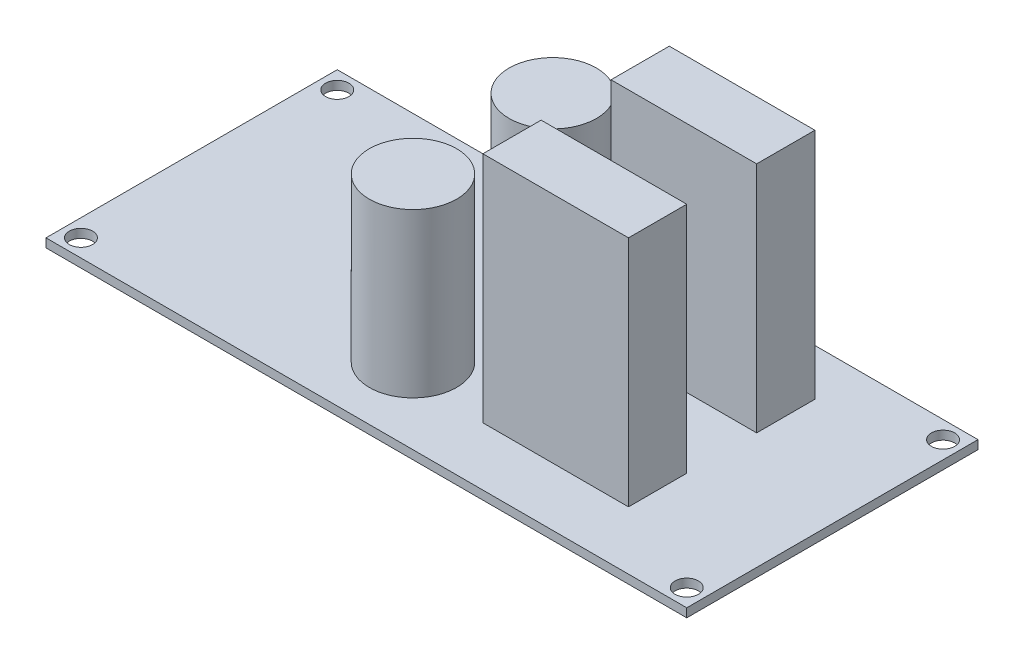
from build123d import *

# Parameters (mm, degrees)
ESBO_O1_W                = 110
ESBO_O1_H                = 50
RESSALTO_EXTRUS_O1_DEPTH = 1.5
ESBO_O2_R                = 2
CORTE_EXTRUS_O1_DEPTH    = 1.5
ESBO_O4_R                = 7.5
ESBO_O4_W                = 25
ESBO_O4_H                = 10
RESSALTO_EXTRUS_O3_DEPTH = 40
ESBO_O5_W                = 39
ESBO_O5_H                = 12
CORTE_EXTRUS_O2_DEPTH    = 60


with BuildPart() as part:
    # Esboço1 → Ressalto-extrusão1 (new body)
    with BuildSketch(Plane(origin=(0, 0, 0), x_dir=(1, 0, 0), z_dir=(0, 1, 0))):
        with Locations((55, 25)):
            Rectangle(ESBO_O1_W, ESBO_O1_H)
    extrude(amount=RESSALTO_EXTRUS_O1_DEPTH)

    # Esboço2 → Corte-extrusão1 (cut)
    with BuildSketch(Plane(origin=(0, 1.5, 0), x_dir=(1, 0, 0), z_dir=(0, 1, 0))):
        with Locations((107, 3)):
            Circle(ESBO_O2_R)
        with Locations((107, 47)):
            Circle(ESBO_O2_R)
        with Locations((3, 3)):
            Circle(ESBO_O2_R)
        with Locations((3, 47)):
            Circle(ESBO_O2_R)
    extrude(amount=-CORTE_EXTRUS_O1_DEPTH, mode=Mode.SUBTRACT)

    # Esboço4 → Ressalto-extrusão3 (add)
    with BuildSketch(Plane(origin=(0, 1.5, 0), x_dir=(1, 0, 0), z_dir=(0, 1, 0))):
        with Locations((50, 37)):
            Circle(ESBO_O4_R)
        with Locations((50, 13)):
            Circle(ESBO_O4_R)
        with Locations((77.5, 37)):
            Rectangle(ESBO_O4_W, ESBO_O4_H)
        with Locations((77.5, 15)):
            Rectangle(ESBO_O4_W, ESBO_O4_H)
    extrude(amount=RESSALTO_EXTRUS_O3_DEPTH)

    # Esboço5 → Corte-extrusão2 (cut)
    with BuildSketch(Plane(origin=(0, 0, 0), x_dir=(0, 0, -1), z_dir=(1, 0, 0))):
        with Locations((25, 35.5)):
            Rectangle(ESBO_O5_W, ESBO_O5_H)
    extrude(amount=CORTE_EXTRUS_O2_DEPTH, mode=Mode.SUBTRACT)


solid = part.part
